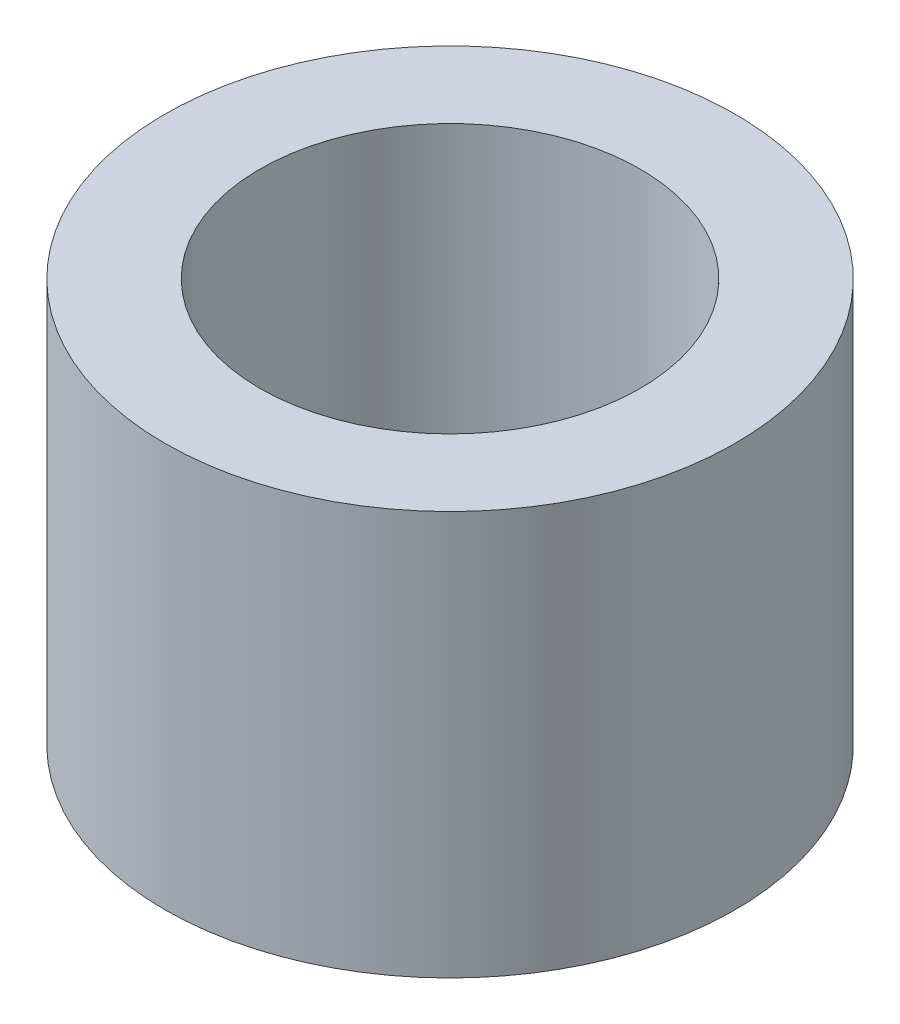
from build123d import *

# Parameters (mm, degrees)
SKETCH1_R           = 6
SKETCH1_R_2         = 4
BOSS_EXTRUDE1_DEPTH = 8.5


with BuildPart() as part:
    # Sketch1 → Boss-Extrude1 (new body)
    with BuildSketch(Plane(origin=(0, 0, 0), x_dir=(1, 0, 0), z_dir=(0, 1, 0))):
        Circle(SKETCH1_R)
        Circle(SKETCH1_R_2, mode=Mode.SUBTRACT)
    extrude(amount=BOSS_EXTRUDE1_DEPTH)


solid = part.part
